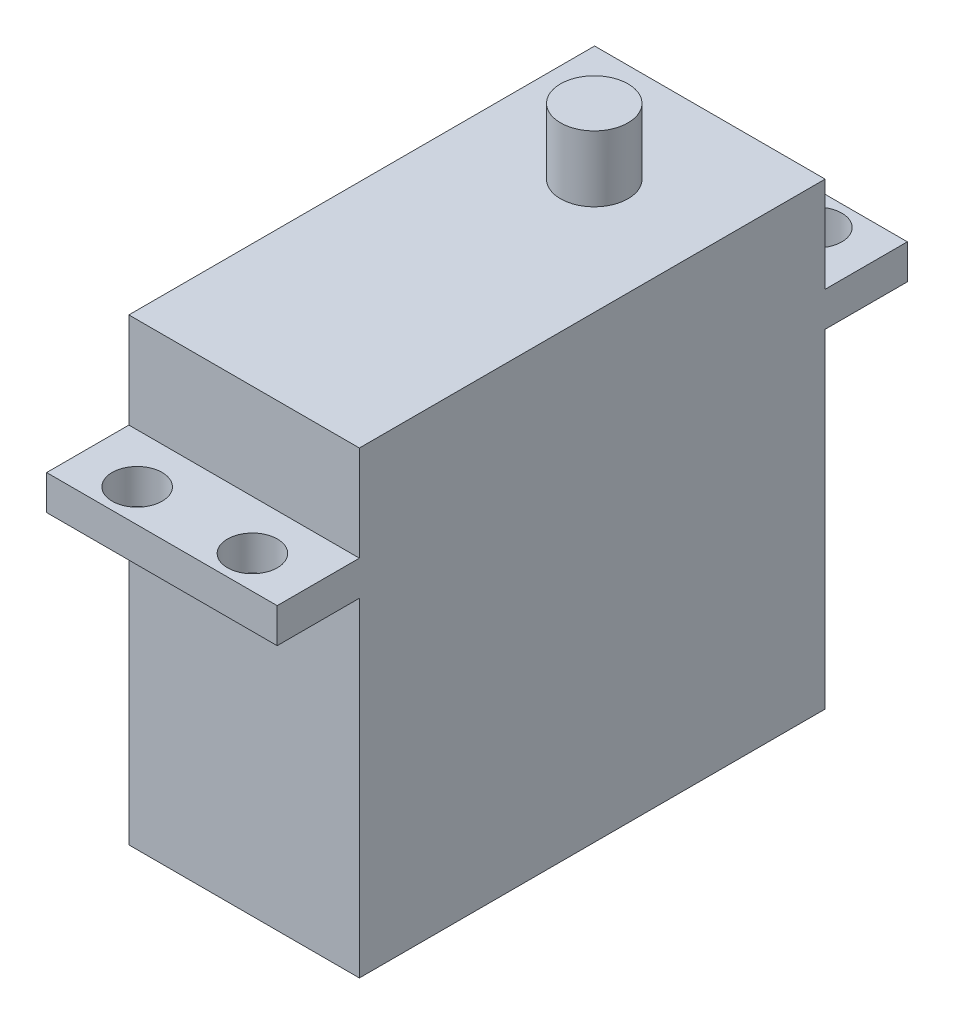
from build123d import *

# Parameters (mm, degrees)
SKETCH1_W   = 19.939
SKETCH1_H   = 40.2844
BODY_DEPTH  = 39.7002
SKETCH2_R   = 2.921
AXLE_DEPTH  = 5.6896
WINGS_START = 28.448
SKETCH3_W   = 19.939
SKETCH3_H   = 7.112
SKETCH3_R   = 2.159
WINGS_DEPTH = 3


with BuildPart() as part:
    # Sketch1 → Body (new body)
    with BuildSketch(Plane(origin=(0, 0, 0), x_dir=(1, 0, 0), z_dir=(0, 1, 0))):
        with Locations((0, -10.1422)):
            Rectangle(SKETCH1_W, SKETCH1_H)
    extrude(amount=BODY_DEPTH)

    # Sketch2 → Axle (add)
    with BuildSketch(Plane(origin=(0, 39.7002, 0), x_dir=(1, 0, 0), z_dir=(0, 1, 0))):
        Circle(SKETCH2_R)
    extrude(amount=AXLE_DEPTH)

    # Sketch3 → Wings (add)
    with BuildSketch(Plane(origin=(0, 0, 0), x_dir=(1, 0, 0), z_dir=(0, 1, 0)).offset(WINGS_START)):
        with Locations((0, 13.556)):
            Rectangle(SKETCH3_W, SKETCH3_H)
        with Locations((4.98475, 14.2672)):
            Circle(SKETCH3_R, mode=Mode.SUBTRACT)
        with Locations((-4.98475, 14.2672)):
            Circle(SKETCH3_R, mode=Mode.SUBTRACT)
    wings = extrude(amount=WINGS_DEPTH)

    # Mirror1: Wings across plane
    add(wings.mirror(Plane.XY.offset(10.1422)))


solid = part.part
